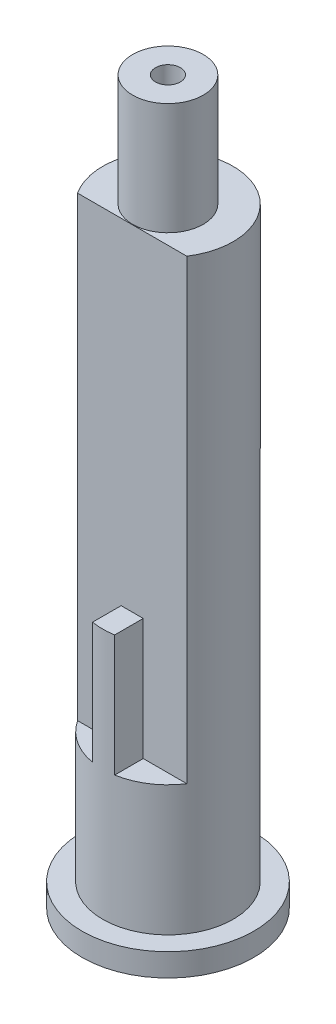
from build123d import *

# Parameters (mm, degrees)
SKETCH1_R             = 6.255
BOTTOM_RING_DEPTH     = 1.66
SKETCH2_R             = 4.755
MAIN_CYLINDER_DEPTH   = 44.41
SKETCH3_R             = 2.57
TOP_CYLINDER_DEPTH    = 52.56
CUTOUT_PT1_DEPTH      = 33.28
CUTOUT_PT2_DEPTH      = 24.44
SKETCH6_R             = 3.47
BOTTOM_HOLE_PT1_DEPTH = 8.82
SKETCH7_R             = 0.905
TOP_HOLE_DEPTH        = 53.56
BOTTOM_HOLE_PT2_DEPTH = 43.23


with BuildPart() as part:
    # Sketch1 → Bottom Ring (new body)
    with BuildSketch(Plane(origin=(0, 0, 0), x_dir=(1, 0, 0), z_dir=(0, 1, 0))):
        Circle(SKETCH1_R)
    extrude(amount=BOTTOM_RING_DEPTH)

    # Sketch2 → Main Cylinder (add)
    with BuildSketch(Plane(origin=(0, 0, 0), x_dir=(1, 0, 0), z_dir=(0, 1, 0))):
        Circle(SKETCH2_R)
    extrude(amount=MAIN_CYLINDER_DEPTH)

    # Sketch3 → Top Cylinder (add)
    with BuildSketch(Plane(origin=(0, 0, 0), x_dir=(1, 0, 0), z_dir=(0, 1, 0))):
        Circle(SKETCH3_R)
    extrude(amount=TOP_CYLINDER_DEPTH)

    # Sketch4 → Cutout pt1 (cut)
    with BuildSketch(Plane(origin=(0, 44.41, 0), x_dir=(1, 0, 0), z_dir=(0, 1, 0))):
        with BuildLine():
            Line((-0.805, -2.605), (-0.805, -4.686363195))
            ThreePointArc((-0.805, -4.686363195), (-2.608092205, -3.97591248), (-3.977939165, -2.605))
            Line((-3.977939165, -2.605), (-0.805, -2.605))
        make_face()
        with BuildLine():
            Line((0.805, -2.605), (0.805, -4.686363195))
            ThreePointArc((0.805, -4.686363195), (2.608092205, -3.97591248), (3.977939165, -2.605))
            Line((3.977939165, -2.605), (0.805, -2.605))
        make_face()
    extrude(amount=-CUTOUT_PT1_DEPTH, mode=Mode.SUBTRACT)

    # Sketch5 → Cutout pt2 (cut)
    with BuildSketch(Plane(origin=(0, 44.41, 0), x_dir=(1, 0, 0), z_dir=(0, 1, 0))):
        with BuildLine():
            Line((-0.805, -2.605), (-0.805, -4.686363195))
            ThreePointArc((-0.805, -4.686363195), (0, -4.755), (0.805, -4.686363195))
            Line((0.805, -4.686363195), (0.805, -2.605))
            Line((0.805, -2.605), (-0.805, -2.605))
        make_face()
    extrude(amount=-CUTOUT_PT2_DEPTH, mode=Mode.SUBTRACT)

    # Sketch6 → Bottom Hole pt1 (cut)
    with BuildSketch(Plane(origin=(0, 0, 0), x_dir=(1, 0, 0), z_dir=(0, 1, 0))):
        Circle(SKETCH6_R)
    extrude(amount=BOTTOM_HOLE_PT1_DEPTH, mode=Mode.SUBTRACT)

    # Sketch7 → Top Hole (cut, through all)
    with BuildSketch(Plane(origin=(0, 52.56, 0), x_dir=(1, 0, 0), z_dir=(0, 1, 0))):
        Circle(SKETCH7_R)
    extrude(amount=-TOP_HOLE_DEPTH, mode=Mode.SUBTRACT)

    # Sketch8 → Bottom Hole pt2 (cut)
    with BuildSketch(Plane(origin=(0, 0, 0), x_dir=(1, 0, 0), z_dir=(0, 1, 0))):
        with BuildLine():
            Line((-3.33456144, -0.96), (3.33456144, -0.96))
            ThreePointArc((3.33456144, -0.96), (0, 3.47), (-3.33456144, -0.96))
        make_face()
    extrude(amount=BOTTOM_HOLE_PT2_DEPTH, mode=Mode.SUBTRACT)


solid = part.part
